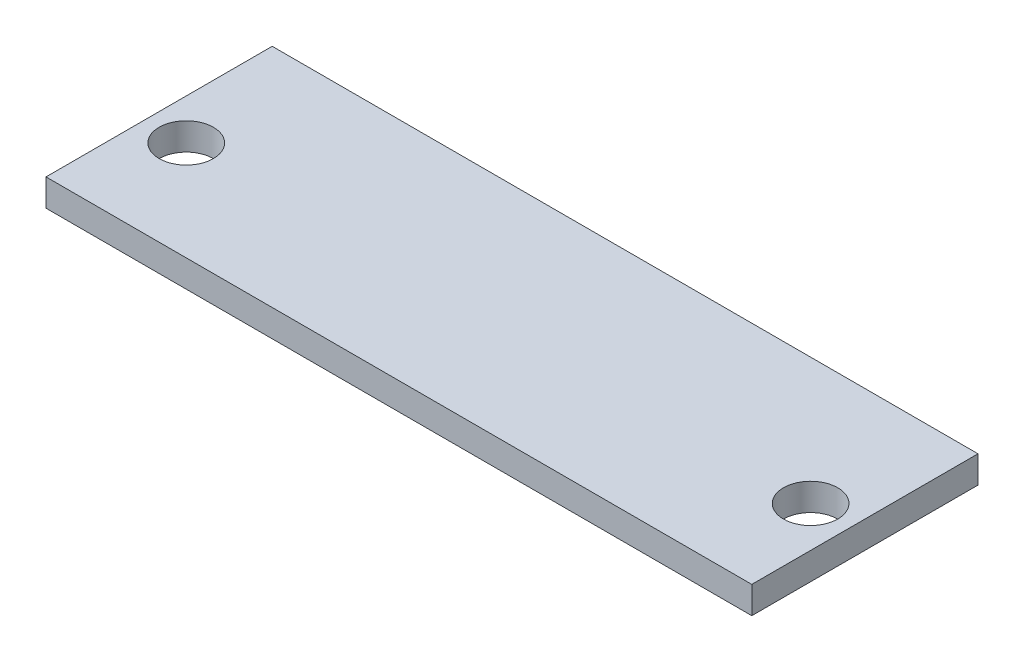
from build123d import *

# Parameters (mm, degrees)
SKETCH1_W           = 78
SKETCH1_H           = 25
SKETCH1_R           = 3
BOSS_EXTRUDE1_DEPTH = 3


with BuildPart() as part:
    # Sketch1 → Boss-Extrude1 (new body)
    with BuildSketch(Plane(origin=(0, 0, 0), x_dir=(1, 0, 0), z_dir=(0, 1, 0))):
        with Locations((-1.967892085, 11.3671875)):
            Rectangle(SKETCH1_W, SKETCH1_H)
        with Locations((-36.467892085, 9.8671875)):
            Circle(SKETCH1_R, mode=Mode.SUBTRACT)
        with Locations((32.532107915, 9.8671875)):
            Circle(SKETCH1_R, mode=Mode.SUBTRACT)
    extrude(amount=BOSS_EXTRUDE1_DEPTH)


solid = part.part
